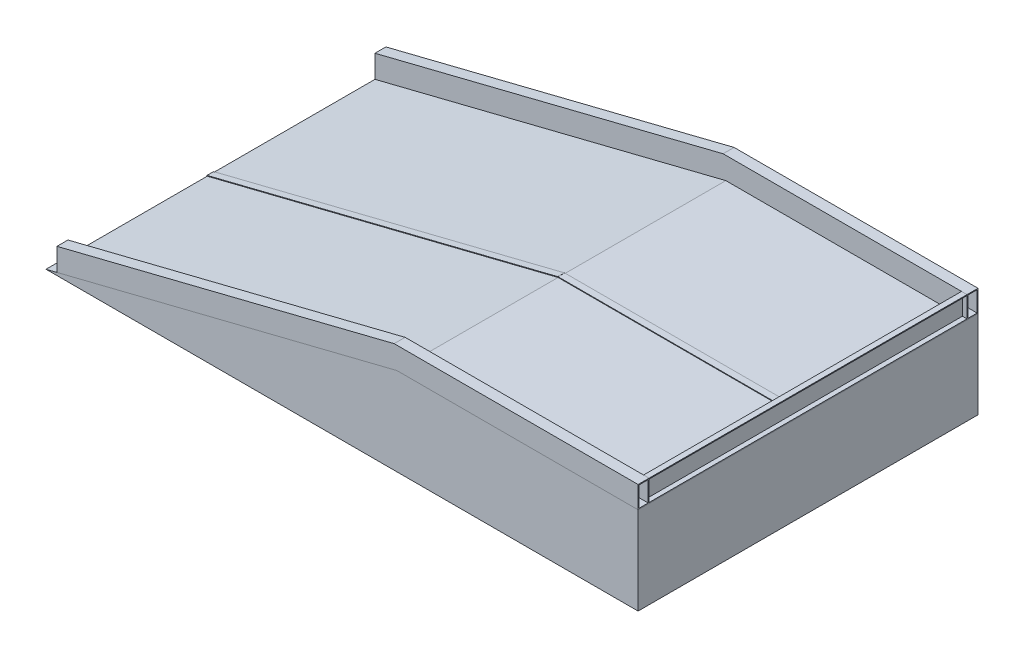
from build123d import *

# Parameters (mm, degrees)
BOSS_EXTRUDE1_DEPTH      = 775
BOSS_EXTRUDE1_DEPTH_BACK = 775
BOSS_EXTRUDE2_DEPTH      = 50
SHELL1_T                 = -4
BOSS_EXTRUDE3_DEPTH      = 50
SHELL2_T                 = -4
SKETCH5_W                = 25
SKETCH5_H                = 1450
BOSS_EXTRUDE4_DEPTH      = 100
SHELL3_T                 = -4
SKETCH7_W                = 1075
SKETCH7_H                = 30
BOSS_EXTRUDE5_DEPTH      = 3
SKETCH8_W                = 1649.242250247
SKETCH8_H                = 30
BOSS_EXTRUDE6_DEPTH      = 3


with BuildPart() as part:
    # Sketch1 → Boss-Extrude1 (new, two sides: drawn at the far end of the back side and taken through both)
    with BuildSketch(Plane.XY.offset(-BOSS_EXTRUDE1_DEPTH_BACK)):
        Polygon((-2700, 0), (0, 0), (0, 400), (-1100, 400), align=None)
    extrude(amount=BOSS_EXTRUDE1_DEPTH + BOSS_EXTRUDE1_DEPTH_BACK)


with BuildPart() as body_2:
    # Sketch3 → Boss-Extrude2 (new body)
    with BuildSketch(Plane.XY.offset(775)):
        Polygon((-2650, 115.57764064), (-2650, 12.5), (-1100, 400), (0, 400), (0, 500), (-1112.310562562, 500), align=None)
    extrude(amount=-BOSS_EXTRUDE2_DEPTH)

    # Shell1
    shell1_openings = [body_2.faces().sort_by_distance(p)[0] for p in [
        (0, 450, 750),
        (-2650, 64.03882032, 750),
    ]]
    offset(amount=SHELL1_T, openings=shell1_openings, kind=Kind.INTERSECTION)


with BuildPart() as body_3:
    # Sketch4 → Boss-Extrude3 (new body)
    with BuildSketch(Plane(origin=(0, 0, -775), x_dir=(-1, 0, 0), z_dir=(0, 0, -1))):
        Polygon((1100, 400), (2650, 12.5), (2700, 0), (2700, 103.07764064), (2650, 115.57764064), (1112.310562562, 500), (0, 500), (0, 400), align=None)
    extrude(amount=-BOSS_EXTRUDE3_DEPTH)

    # Shell2
    shell2_openings = [body_3.faces().sort_by_distance(p)[0] for p in [
        (-2700, 51.53882032, -750),
        (0, 450, -750),
    ]]
    offset(amount=SHELL2_T, openings=shell2_openings, kind=Kind.INTERSECTION)


with BuildPart() as body_4:
    # Sketch5 → Boss-Extrude4 (new body)
    with BuildSketch(Plane(origin=(0, 400, 0), x_dir=(1, 0, 0), z_dir=(0, 1, 0))):
        with Locations((-12.5, 0)):
            Rectangle(SKETCH5_W, SKETCH5_H)
    extrude(amount=BOSS_EXTRUDE4_DEPTH)

    # Shell3
    shell3_openings = [body_4.faces().sort_by_distance(p)[0] for p in [
        (-12.5, 450, -725),
        (0, 450, 0),
        (-12.5, 450, 725),
    ]]
    offset(amount=SHELL3_T, openings=shell3_openings, kind=Kind.INTERSECTION)


with BuildPart() as body_5:
    # Sketch7 → Boss-Extrude5 (new body)
    with BuildSketch(Plane(origin=(0, 400, 0), x_dir=(1, 0, 0), z_dir=(0, 1, 0))):
        with Locations((-562.5, -25)):
            Rectangle(SKETCH7_W, SKETCH7_H)
    extrude(amount=BOSS_EXTRUDE5_DEPTH)


with BuildPart() as body_6:
    # Sketch8 → Boss-Extrude6 (new body)
    with BuildSketch(Plane(origin=(-158.823529412, 635.294117647, 0), x_dir=(0.970142500145332, 0.24253562503633297, 0), z_dir=(-0.24253562503633297, 0.970142500145332, 0))):
        with Locations((-1794.763625269, -25)):
            Rectangle(SKETCH8_W, SKETCH8_H)
    extrude(amount=BOSS_EXTRUDE6_DEPTH)


solid = Compound([part.part, body_2.part, body_3.part, body_4.part, body_5.part, body_6.part])
